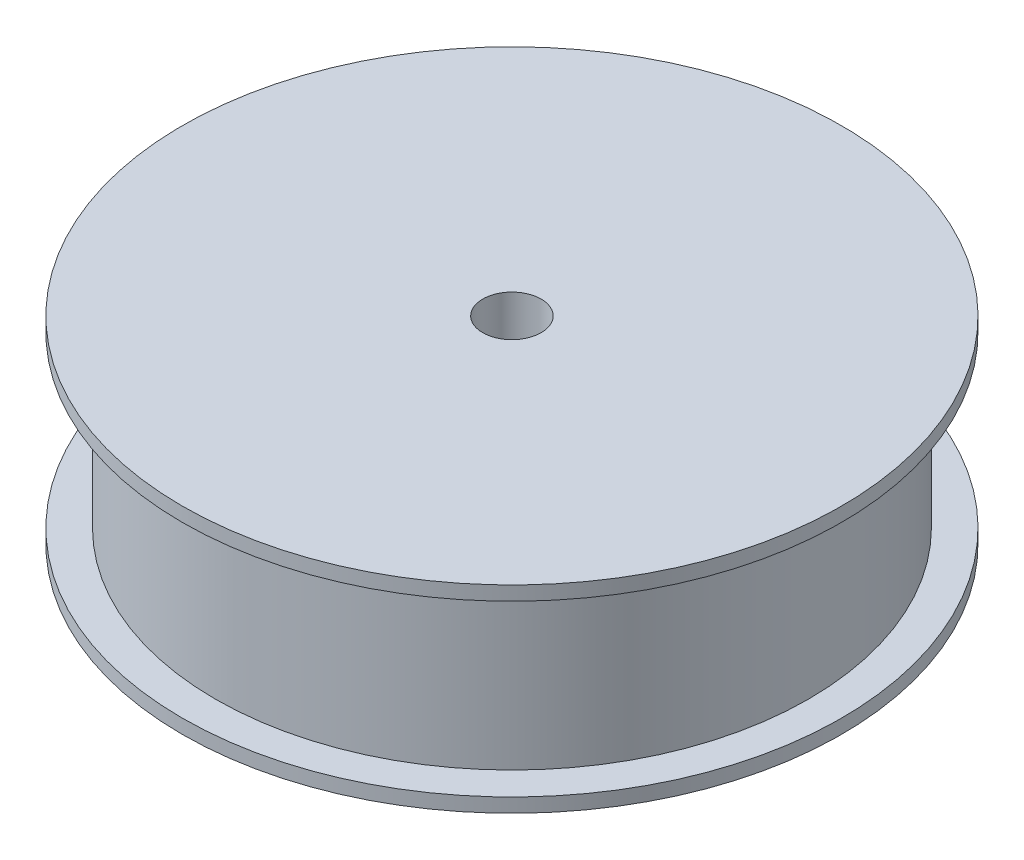
from build123d import *

# Parameters (mm, degrees)
SKETCH1_R           = 35
BOSS_EXTRUDE1_DEPTH = 1.5
SKETCH2_R           = 31.5
BOSS_EXTRUDE2_DEPTH = 18
SKETCH3_R           = 35
BOSS_EXTRUDE3_DEPTH = 1.5
SKETCH4_R           = 3.1
CUT_EXTRUDE1_DEPTH  = 22


with BuildPart() as part:
    # Sketch1 → Boss-Extrude1 (new body)
    with BuildSketch(Plane(origin=(0, 0, 0), x_dir=(1, 0, 0), z_dir=(0, 1, 0))):
        Circle(SKETCH1_R)
    extrude(amount=BOSS_EXTRUDE1_DEPTH)

    # Sketch2 → Boss-Extrude2 (add)
    with BuildSketch(Plane(origin=(0, 1.5, 0), x_dir=(1, 0, 0), z_dir=(0, 1, 0))):
        Circle(SKETCH2_R)
    extrude(amount=BOSS_EXTRUDE2_DEPTH)

    # Sketch3 → Boss-Extrude3 (add)
    with BuildSketch(Plane(origin=(0, 19.5, 0), x_dir=(1, 0, 0), z_dir=(0, 1, 0))):
        Circle(SKETCH3_R)
    extrude(amount=BOSS_EXTRUDE3_DEPTH)

    # Sketch4 → Cut-Extrude1 (cut, through all)
    with BuildSketch(Plane(origin=(0, 21, 0), x_dir=(1, 0, 0), z_dir=(0, 1, 0))):
        Circle(SKETCH4_R)
    extrude(amount=-CUT_EXTRUDE1_DEPTH, mode=Mode.SUBTRACT)


solid = part.part
